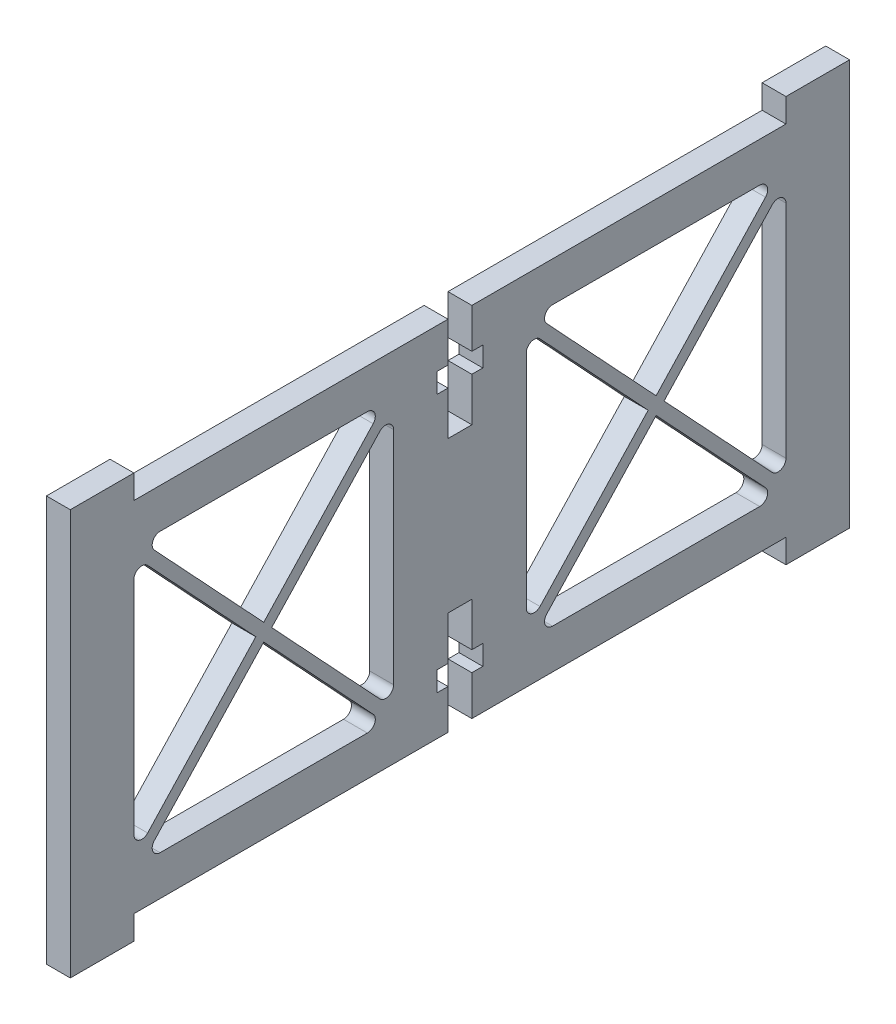
from build123d import *

# Parameters (mm, degrees)
RESSALTO_EXTRUS_O1_DEPTH = 3


with BuildPart() as part:
    # Esboço1 → Ressalto-extrusão1 (new body)
    with BuildSketch(Plane(origin=(0, 0, 0), x_dir=(0, 0, -1), z_dir=(1, 0, 0))):
        Polygon((49, 1.499999999), (41, 1.499999999), (41, -1.500000001), (33.485947172, -1.500000001), (1.5, -1.500000001), (1.5, -6.500000001), (2.875, -6.500000001), (2.875, -9.000000001), (1.5, -9.000000001), (1.5, -14.500000001), (-1.5, -14.500000001), (-1.5, -9.000000001), (-2.875, -9.000000001), (-2.875, -6.500000001), (-1.5, -6.500000001), (-1.5, -1.500000001), (-40.999999999, -1.500000001), (-40.999999999, 1.499999999), (-48.999999999, 1.499999999), (-48.999999999, -1.500000001), (-48.999999999, -46.500000001), (-48.999999999, -49.500000001), (-40.999999999, -49.500000001), (-40.999999999, -46.500000001), (-1.5, -46.500000001), (-1.5, -41.500000001), (-2.875, -41.500000001), (-2.875, -39.000000001), (-1.5, -39.000000001), (-1.5, -33.500000001), (1.5, -33.500000001), (1.5, -39.000000001), (2.875, -39.000000001), (2.875, -41.500000001), (1.5, -41.500000001), (1.5, -46.500000001), (33.485947172, -46.500000001), (41, -46.500000001), (41, -49.5), (49, -49.5), (49, -46.500000001), (49, -24.000000001), (49, -1.500000001), align=None)
        with BuildLine():
            Line((-40.999999999, -10.109163073), (-40.999999999, -37.890836928))
            ThreePointArc((-40.999999999, -37.890836928), (-40.366648114, -38.821196622), (-39.26886168, -38.573066184))
            Line((-39.26886168, -38.573066184), (-25.670652093, -24.000000001))
            Line((-25.670652093, -24.000000001), (-39.26886168, -9.426933817))
            ThreePointArc((-39.26886168, -9.426933817), (-40.366648114, -9.17880338), (-40.999999999, -10.109163073))
        make_face(mode=Mode.SUBTRACT)
        with BuildLine():
            Line((-37.699164149, -41.500000001), (-11.642140036, -41.500000001))
            ThreePointArc((-11.642140036, -41.500000001), (-10.725017019, -40.898604281), (-10.911001717, -39.817770745))
            Line((-10.911001717, -39.817770745), (-24.670652093, -25.071690071))
            Line((-24.670652093, -25.071690071), (-38.430302469, -39.817770745))
            ThreePointArc((-38.430302469, -39.817770745), (-38.616287166, -40.898604281), (-37.699164149, -41.500000001))
        make_face(mode=Mode.SUBTRACT)
        with BuildLine():
            Line((-8.341304186, -37.890836928), (-8.341304186, -10.109163073))
            ThreePointArc((-8.341304186, -10.109163073), (-8.974656071, -9.17880338), (-10.072442506, -9.426933817))
            Line((-10.072442506, -9.426933817), (-23.670652093, -24.000000001))
            Line((-23.670652093, -24.000000001), (-10.072442506, -38.573066184))
            ThreePointArc((-10.072442506, -38.573066184), (-8.974656071, -38.821196622), (-8.341304186, -37.890836928))
        make_face(mode=Mode.SUBTRACT)
        with BuildLine():
            Line((-11.642140036, -6.500000001), (-37.699164149, -6.500000001))
            ThreePointArc((-37.699164149, -6.500000001), (-38.616287166, -7.101395721), (-38.430302469, -8.182229257))
            Line((-38.430302469, -8.182229257), (-24.670652093, -22.928309931))
            Line((-24.670652093, -22.928309931), (-10.911001717, -8.182229257))
            ThreePointArc((-10.911001717, -8.182229257), (-10.725017019, -7.101395721), (-11.642140036, -6.500000001))
        make_face(mode=Mode.SUBTRACT)
        with BuildLine():
            Line((10.911001717, -8.182229257), (24.670652093, -22.928309931))
            Line((24.670652093, -22.928309931), (38.430302469, -8.182229257))
            ThreePointArc((38.430302469, -8.182229257), (38.616287166, -7.101395721), (37.699164149, -6.500000001))
            Line((37.699164149, -6.500000001), (11.642140036, -6.500000001))
            ThreePointArc((11.642140036, -6.500000001), (10.725017019, -7.101395721), (10.911001717, -8.182229257))
        make_face(mode=Mode.SUBTRACT)
        with BuildLine():
            Line((10.072442506, -9.426933817), (23.670652093, -24.000000001))
            Line((23.670652093, -24.000000001), (10.072442506, -38.573066184))
            ThreePointArc((10.072442506, -38.573066184), (8.974656071, -38.821196622), (8.341304186, -37.890836928))
            Line((8.341304186, -37.890836928), (8.341304186, -10.109163073))
            ThreePointArc((8.341304186, -10.109163073), (8.974656071, -9.17880338), (10.072442506, -9.426933817))
        make_face(mode=Mode.SUBTRACT)
        with BuildLine():
            Line((25.670652093, -24.000000001), (39.26886168, -9.426933817))
            ThreePointArc((39.26886168, -9.426933817), (40.366648114, -9.17880338), (40.999999999, -10.109163073))
            Line((40.999999999, -10.109163073), (40.999999999, -37.890836928))
            ThreePointArc((40.999999999, -37.890836928), (40.366648114, -38.821196622), (39.26886168, -38.573066184))
            Line((39.26886168, -38.573066184), (25.670652093, -24.000000001))
        make_face(mode=Mode.SUBTRACT)
        with BuildLine():
            Line((24.670652093, -25.071690071), (10.911001717, -39.817770745))
            ThreePointArc((10.911001717, -39.817770745), (10.725017019, -40.898604281), (11.642140036, -41.500000001))
            Line((11.642140036, -41.500000001), (37.699164149, -41.500000001))
            ThreePointArc((37.699164149, -41.500000001), (38.616287166, -40.898604281), (38.430302469, -39.817770745))
            Line((38.430302469, -39.817770745), (24.670652093, -25.071690071))
        make_face(mode=Mode.SUBTRACT)
    extrude(amount=RESSALTO_EXTRUS_O1_DEPTH)


solid = part.part
